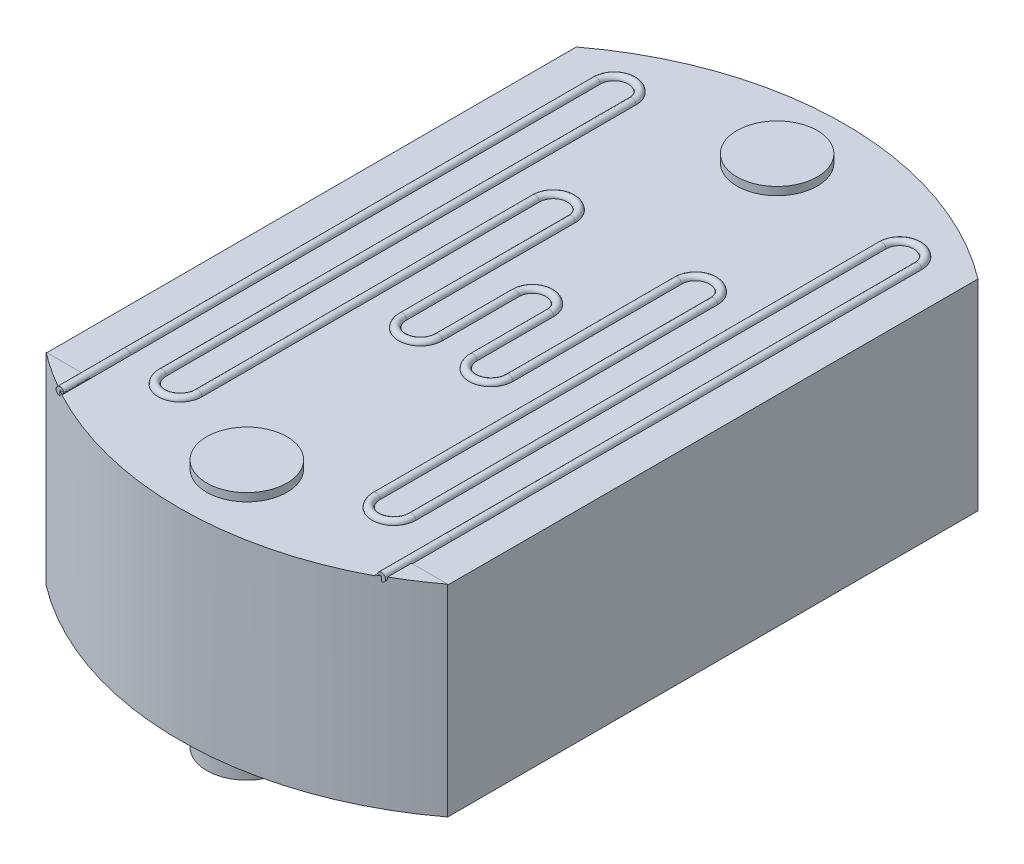
from build123d import *

# Parameters (mm, degrees)
SKETCH1_W                    = 2.5
SKETCH1_H                    = 3.3
MAIN_HEAD_DEPTH              = 1.25
SKETCH2_R                    = 0.25
WIRE_EXTRUSIONS_TOP_DEPTH    = 0.05
LINES_TOP_PROFILE_R          = 0.025
TRIANGLE_PATTERN_TOP_DEPTH   = 0.005
SKETCH40_R                   = 0.25
WIRE_EXTRUSIONS_BOTTOM_DEPTH = 0.25


with BuildPart() as part:
    # Sketch1 → main head (new body)
    with BuildSketch(Plane(origin=(0, 0, 0), x_dir=(1, 0, 0), z_dir=(0, 1, 0))):
        with BuildLine():
            Line((0, 0), (2.5, 0))
            ThreePointArc((2.5, 0), (1.25, -0.420024154), (0, 0))
        make_face()
        with Locations((1.25, 1.65)):
            Rectangle(SKETCH1_W, SKETCH1_H)
        with BuildLine():
            ThreePointArc((0, 3.3), (1.25, 3.720024154), (2.5, 3.3))
            Line((2.5, 3.3), (0, 3.3))
        make_face()
    extrude(amount=MAIN_HEAD_DEPTH)

    # Sketch2 → wire extrusions - top (add)
    with BuildSketch(Plane(origin=(0, 1.25, 0), x_dir=(1, 0, 0), z_dir=(0, 1, 0))):
        with Locations((1.25, 0)):
            Circle(SKETCH2_R)
        with Locations((1.25, 3.3)):
            Circle(SKETCH2_R)
    extrude(amount=WIRE_EXTRUSIONS_TOP_DEPTH)

    # lines top: sweep along a path in Sketch4
    with BuildLine(Plane(origin=(0, 1.25, 0), x_dir=(1, 0, 0), z_dir=(0, 1, 0))) as lines_top_path:
        Line((0.25, -0.162456896), (0.25, 0.25))
        Line((0.25, 0.25), (0.25, 3.175))
        ThreePointArc((0.25, 3.175), (0.3615, 3.2865), (0.473, 3.175))
        Line((0.473, 3.175), (0.473, 0.25))
        ThreePointArc((0.473, 0.25), (0.5845, 0.1385), (0.696, 0.25))
        Line((0.696, 0.25), (0.696, 2.35))
        ThreePointArc((0.696, 2.35), (0.8075, 2.4615), (0.919, 2.35))
        Line((0.919, 2.35), (0.919, 1.3))
        ThreePointArc((0.919, 1.3), (1.0305, 1.1885), (1.142, 1.3))
        Line((1.142, 1.3), (1.142, 1.77737971))
        ThreePointArc((1.142, 1.77737971), (1.25, 1.88537971), (1.358, 1.77737971))
        Line((1.358, 1.77737971), (1.358, 1.3))
        ThreePointArc((1.358, 1.3), (1.4695, 1.1885), (1.581, 1.3))
        Line((1.581, 1.3), (1.581, 2.35))
        ThreePointArc((1.581, 2.35), (1.6925, 2.4615), (1.804, 2.35))
        Line((1.804, 2.35), (1.804, 0.25))
        ThreePointArc((1.804, 0.25), (1.9155, 0.1385), (2.027, 0.25))
        Line((2.027, 0.25), (2.027, 3.175))
        ThreePointArc((2.027, 3.175), (2.1385, 3.2865), (2.25, 3.175))
        Line((2.25, 3.175), (2.25, 0.249162513))
        Line((2.25, 0.249162513), (2.25, -0.162456896))
    # lines top profile (on start of the path) → lines top (sweep)
    with BuildSketch(Plane(origin=(0.25, 1.25, 0.162456896), x_dir=(-1, 0, 0), z_dir=(0, 0, -1))):
        Circle(LINES_TOP_PROFILE_R)
    sweep(path=lines_top_path.line)

    # Sketch37 → triangle pattern - top (add)
    with BuildSketch(Plane(origin=(0, 1.25, 0), x_dir=(1, 0, 0), z_dir=(0, 1, 0))):
        with BuildLine():
            Line((2.5, 0), (2.225, 0))
            Line((2.225, 0), (2.225, -0.176027108))
            ThreePointArc((2.225, -0.176027108), (2.365976091, -0.09344411), (2.5, 0))
        make_face()
        with BuildLine():
            Line((0.275, 0), (0, 0))
            ThreePointArc((0, 0), (0.134023909, -0.09344411), (0.275, -0.176027108))
            Line((0.275, -0.176027108), (0.275, 0))
        make_face()
    extrude(amount=TRIANGLE_PATTERN_TOP_DEPTH)

    # Sketch40 → wire extrusions - bottom (add)
    with BuildSketch(Plane.XZ):
        with Locations((1.25, -3.3)):
            Circle(SKETCH40_R)
        with Locations((1.25, 0)):
            Circle(SKETCH40_R)
    extrude(amount=WIRE_EXTRUSIONS_BOTTOM_DEPTH)


solid = part.part
